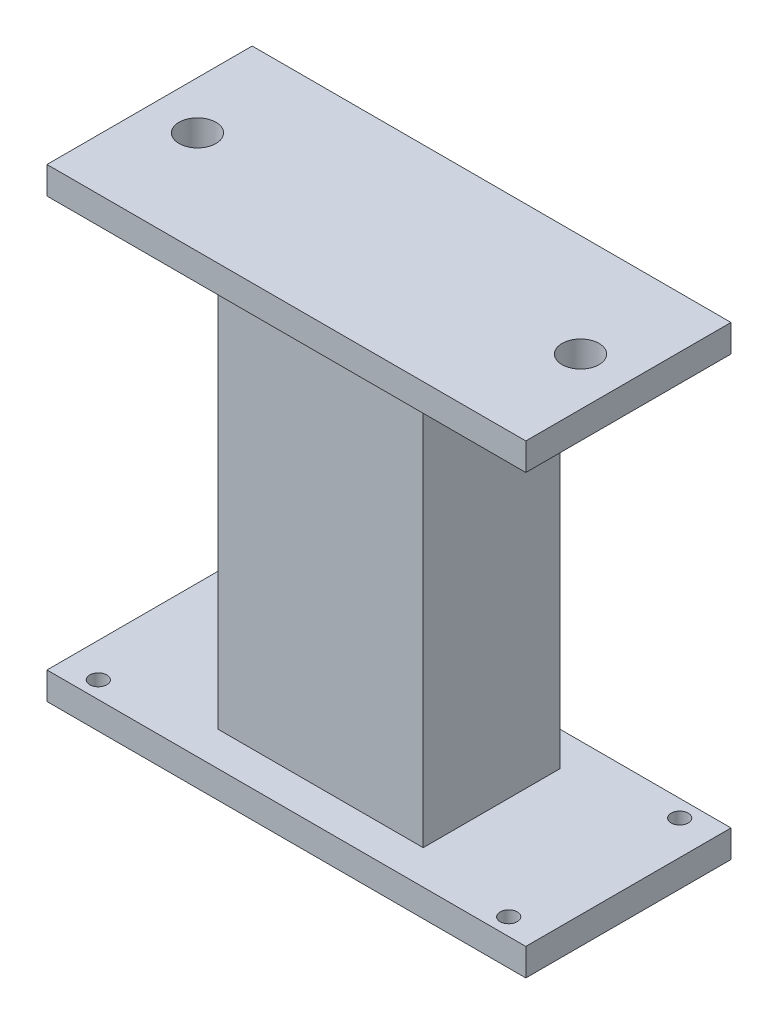
from build123d import *

# Parameters (mm, degrees)
SKETCH2_W           = 70
SKETCH2_H           = 30
SKETCH2_R           = 1.25
BOSS_EXTRUDE1_DEPTH = 4
SKETCH4_W           = 30
SKETCH4_H           = 20
BOSS_EXTRUDE2_DEPTH = 60.0001011
SKETCH5_W           = 70
SKETCH5_H           = 30
SKETCH5_R           = 2.7
BOSS_EXTRUDE3_DEPTH = 4


with BuildPart() as part:
    # Sketch2 → Boss-Extrude1 (new body)
    with BuildSketch(Plane(origin=(0, 0, 0), x_dir=(1, 0, 0), z_dir=(0, 1, 0))):
        Rectangle(SKETCH2_W, SKETCH2_H)
        with Locations((-30, -12.5)):
            Circle(SKETCH2_R, mode=Mode.SUBTRACT)
        with Locations((-30, 12.5)):
            Circle(SKETCH2_R, mode=Mode.SUBTRACT)
        with Locations((30, -12.5)):
            Circle(SKETCH2_R, mode=Mode.SUBTRACT)
        with Locations((30, 12.5)):
            Circle(SKETCH2_R, mode=Mode.SUBTRACT)
    extrude(amount=BOSS_EXTRUDE1_DEPTH)

    # Sketch4 → Boss-Extrude2 (add)
    with BuildSketch(Plane(origin=(0, 4, 0), x_dir=(1, 0, 0), z_dir=(0, 1, 0))):
        Rectangle(SKETCH4_W, SKETCH4_H)
    extrude(amount=BOSS_EXTRUDE2_DEPTH)

    # Sketch5 → Boss-Extrude3 (add)
    with BuildSketch(Plane(origin=(0, 64.0001011, 0), x_dir=(1, 0, 0), z_dir=(0, 1, 0))):
        Rectangle(SKETCH5_W, SKETCH5_H)
        with Locations((-28, 0)):
            Circle(SKETCH5_R, mode=Mode.SUBTRACT)
        with Locations((28, 0)):
            Circle(SKETCH5_R, mode=Mode.SUBTRACT)
    extrude(amount=BOSS_EXTRUDE3_DEPTH)


solid = part.part
